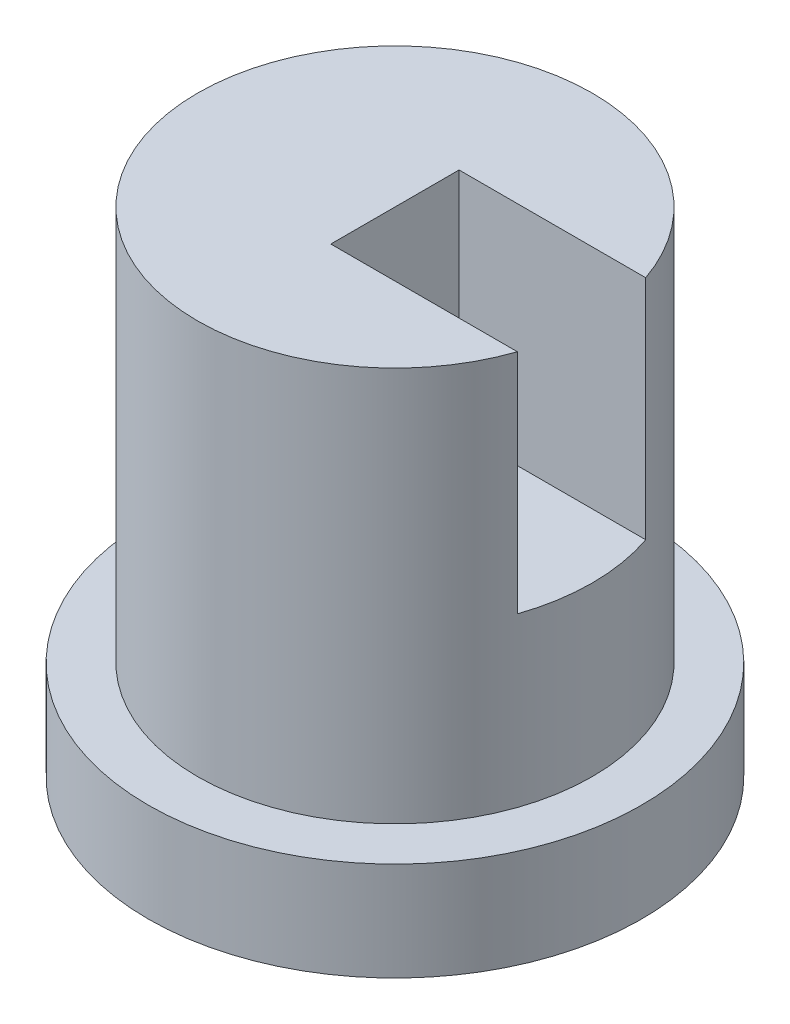
from build123d import *

# Parameters (mm, degrees)
CROQUIS1_R              = 25
SALIENTE_EXTRUIR1_DEPTH = 10
CROQUIS2_R              = 20
SALIENTE_EXTRUIR3_DEPTH = 40
CROQUIS4_W              = 13
CROQUIS4_H              = 23
CORTAR_EXTRUIR2_DEPTH   = 40


with BuildPart() as part:
    # Croquis1 → Saliente-Extruir1 (new body)
    with BuildSketch(Plane(origin=(0, 0, 0), x_dir=(1, 0, 0), z_dir=(0, 1, 0))):
        Circle(CROQUIS1_R)
    extrude(amount=SALIENTE_EXTRUIR1_DEPTH)

    # Croquis2 → Saliente-Extruir3 (add)
    with BuildSketch(Plane(origin=(0, 10, 0), x_dir=(1, 0, 0), z_dir=(0, 1, 0))):
        Circle(CROQUIS2_R)
    extrude(amount=SALIENTE_EXTRUIR3_DEPTH)

    # Croquis4 → Cortar-Extruir2 (cut)
    with BuildSketch(Plane(origin=(0, 0, 0), x_dir=(0, 0, -1), z_dir=(1, 0, 0))):
        with Locations((0, 38.5)):
            Rectangle(CROQUIS4_W, CROQUIS4_H)
    extrude(amount=CORTAR_EXTRUIR2_DEPTH, mode=Mode.SUBTRACT)


solid = part.part
